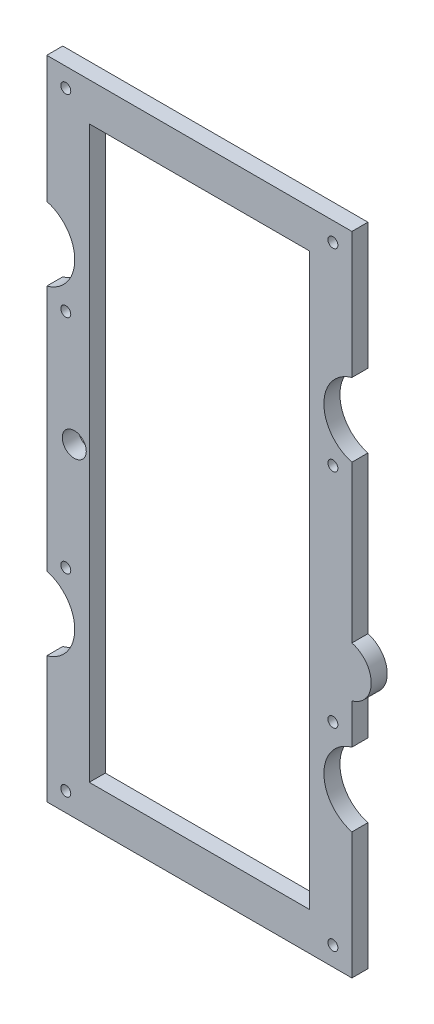
from build123d import *

# Parameters (mm, degrees)
SKETCH1_R           = 2.5
BOSS_EXTRUDE1_DEPTH = 8
SKETCH5_W           = 110
SKETCH5_H           = 285
CUT_EXTRUDE4_DEPTH  = 9
SKETCH6_R           = 6
CUT_EXTRUDE5_DEPTH  = 9


with BuildPart() as part:
    # Sketch1 → Boss-Extrude1 (new body)
    with BuildSketch(Plane.XY):
        with BuildLine():
            Line((-61.080112923, -938.33030278), (-61.080112923, -1061.66969722))
            ThreePointArc((-61.080112923, -1061.66969722), (-47.080112923, -1080), (-61.080112923, -1098.33030278))
            Line((-61.080112923, -1098.33030278), (-61.080112923, -1161.56262))
            Line((-61.080112923, -1161.56262), (91.419887077, -1161.56262))
            Line((91.419887077, -1161.56262), (91.419887077, -1098.33030278))
            ThreePointArc((91.419887077, -1098.33030278), (77.419887077, -1080), (91.419887077, -1061.66969722))
            Line((91.419887077, -1061.66969722), (91.419887077, -1041.596868336))
            ThreePointArc((91.419887077, -1041.596868336), (101.085308187, -1029.0799835), (91.419887077, -1016.563098664))
            Line((91.419887077, -1016.563098664), (91.419887077, -938.33030278))
            ThreePointArc((91.419887077, -938.33030278), (77.419887077, -920), (91.419887077, -901.66969722))
            Line((91.419887077, -901.66969722), (91.419887077, -838.43738))
            Line((91.419887077, -838.43738), (-61.080112923, -838.43738))
            Line((-61.080112923, -838.43738), (-61.080112923, -901.66969722))
            ThreePointArc((-61.080112923, -901.66969722), (-47.080112923, -920), (-61.080112923, -938.33030278))
        make_face()
        with Locations((-51.580112923, -847.93738)):
            Circle(SKETCH1_R, mode=Mode.SUBTRACT)
        with Locations((81.919887077, -847.93738)):
            Circle(SKETCH1_R, mode=Mode.SUBTRACT)
        with Locations((81.919887077, -944.535688293)):
            Circle(SKETCH1_R, mode=Mode.SUBTRACT)
        with Locations((-51.580112923, -944.535688293)):
            Circle(SKETCH1_R, mode=Mode.SUBTRACT)
        with Locations((-51.580112923, -1055.464311707)):
            Circle(SKETCH1_R, mode=Mode.SUBTRACT)
        with Locations((81.919887077, -1055.464311707)):
            Circle(SKETCH1_R, mode=Mode.SUBTRACT)
        with Locations((81.919887077, -1152.06262)):
            Circle(SKETCH1_R, mode=Mode.SUBTRACT)
        with Locations((-51.580112923, -1152.06262)):
            Circle(SKETCH1_R, mode=Mode.SUBTRACT)
    extrude(amount=BOSS_EXTRUDE1_DEPTH)

    # Sketch5 → Cut-Extrude4 (cut, through all)
    with BuildSketch(Plane(origin=(0, 0, 0), x_dir=(-1, 0, 0), z_dir=(0, 0, -1))):
        with Locations((-15.169887077, -1000)):
            Rectangle(SKETCH5_W, SKETCH5_H)
    extrude(amount=-CUT_EXTRUDE4_DEPTH, mode=Mode.SUBTRACT)

    # Sketch6 → Cut-Extrude5 (cut, through all)
    with BuildSketch(Plane.XY.offset(8)):
        with Locations((-47.330112923, -1000)):
            Circle(SKETCH6_R)
    extrude(amount=-CUT_EXTRUDE5_DEPTH, mode=Mode.SUBTRACT)


solid = part.part
